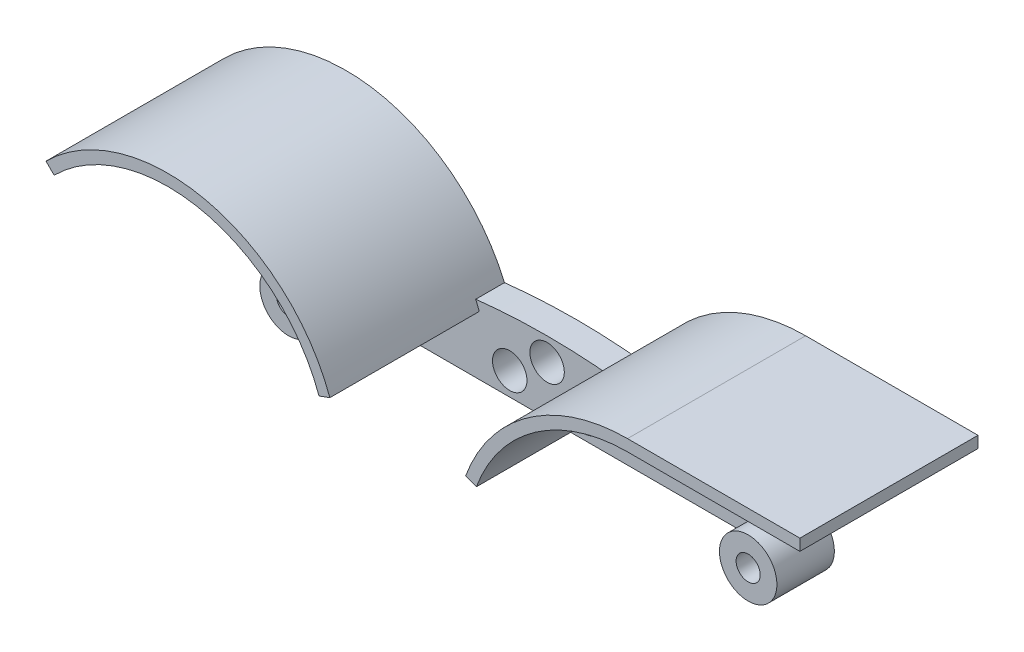
from build123d import *

# Parameters (mm, degrees)
BOSS_EXTRUDE1_DEPTH = 5
SKETCH3_R           = 5
BOSS_EXTRUDE2_DEPTH = 5
BOSS_EXTRUDE3_DEPTH = 2
BOSS_EXTRUDE5_DEPTH = 29
SKETCH6_R           = 2.1
SKETCH6_R_2         = 3
CUT_EXTRUDE1_DEPTH  = 11


with BuildPart() as part:
    # Sketch2 → Boss-Extrude1 (new body)
    with BuildSketch(Plane.XY):
        with BuildLine():
            Line((-35, -12.5), (35, -12.5))
            ThreePointArc((35, -12.5), (43.535533906, -16.035533906), (40, -7.5))
            ThreePointArc((40, -7.5), (0, 0), (-40, -7.5))
            ThreePointArc((-40, -7.5), (-43.535533906, -16.035533906), (-35, -12.5))
        make_face()
    extrude(amount=BOSS_EXTRUDE1_DEPTH)

    # Sketch3 → Boss-Extrude2 (add)
    with BuildSketch(Plane.XY.offset(5)):
        with Locations((-40, -12.5)):
            Circle(SKETCH3_R)
        with Locations(Location((40, -12.5, 0), (0, 0, 180))):  # turned: the seam where the file's is
            Circle(SKETCH3_R)
    extrude(amount=BOSS_EXTRUDE2_DEPTH)

    # Sketch4 → Boss-Extrude3 (add)
    with BuildSketch(Plane(origin=(0, 0, 0), x_dir=(-1, 0, 0), z_dir=(0, 0, -1))):
        with BuildLine():
            Line((-40, 17.5), (-70, 17.5))
            Line((-70, 17.5), (-70, 15.5))
            Line((-70, 15.5), (-43.655276341, -9.088408748))
            ThreePointArc((-43.655276341, -9.088408748), (-41.992742299, -7.914263622), (-40, -7.5))
            ThreePointArc((-40, -7.5), (-26.428535361, -3.209517668), (-12.417905405, -0.700506038))
            ThreePointArc((-12.417905405, -0.700506038), (-23.477058659, 12.539816482), (-40, 17.5))
        make_face()
        with BuildLine():
            ThreePointArc((61.213203436, 8.713203436), (34.317115595, 16.95682985), (12.417905405, -0.700506038))
            ThreePointArc((12.417905405, -0.700506038), (26.428535361, -3.209517668), (40, -7.5))
            ThreePointArc((40, -7.5), (41.913417162, -7.880602337), (43.535533906, -8.964466094))
            Line((43.535533906, -8.964466094), (61.213203436, 8.713203436))
        make_face()
    extrude(amount=-BOSS_EXTRUDE3_DEPTH)

    # Sketch5 → Boss-Extrude5 (add)
    with BuildSketch(Plane.XY.offset(2)):
        with BuildLine():
            Line((-59.798989873, 7.298989873), (-61.213203436, 8.713203436))
            ThreePointArc((-61.213203436, 8.713203436), (-33.506811582, 16.788880214), (-11.809221376, -2.2393957))
            Line((-11.809221376, -2.2393957), (-13.688606618, -2.923435987))
            ThreePointArc((-13.688606618, -2.923435987), (-33.93969081, 14.836288199), (-59.798989873, 7.298989873))
        make_face()
        with BuildLine():
            Line((40, 17.5), (70, 17.5))
            Line((70, 17.5), (70, 15.5))
            Line((70, 15.5), (40, 15.5))
            ThreePointArc((40, 15.5), (23.939859782, 10.43625724), (13.688606618, -2.923435987))
            Line((13.688606618, -2.923435987), (11.809221376, -2.2393957))
            ThreePointArc((11.809221376, -2.2393957), (22.792706909, 12.074561329), (40, 17.5))
        make_face()
    extrude(amount=BOSS_EXTRUDE5_DEPTH)

    # Sketch6 → Cut-Extrude1 (cut, through all)
    with BuildSketch(Plane.XY.offset(10)):
        with Locations((-40, -12.5)):
            Circle(SKETCH6_R)
        with Locations((40, -12.5)):
            Circle(SKETCH6_R)
        with Locations((0, -4)):
            Circle(SKETCH6_R_2)
        with Locations((-6.5, -8.5)):
            Circle(SKETCH6_R_2)
        with Locations((6.5, -8.5)):
            Circle(SKETCH6_R_2)
    extrude(amount=-CUT_EXTRUDE1_DEPTH, mode=Mode.SUBTRACT)


solid = part.part
